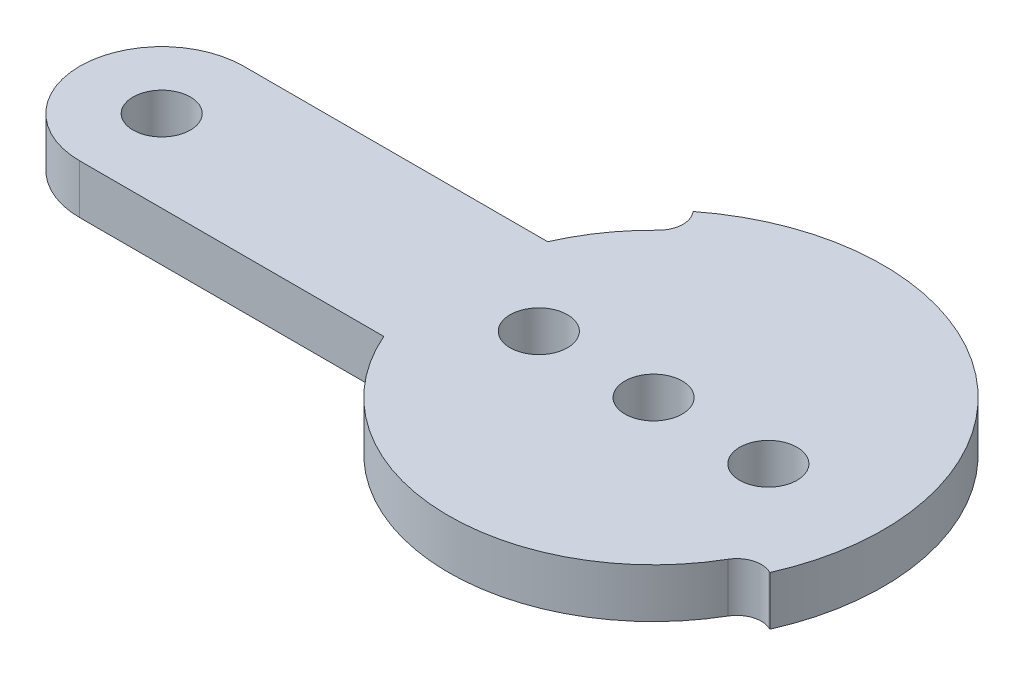
from build123d import *

# Parameters (mm, degrees)
SKETCH_1_R          = 1.75
EXTRUDE_1_DEPTH     = 3
SKETCH_2_R          = 6
EXTRUDE_2_DEPTH     = 3
SKETCH_3_R          = 1.75
CUT_EXTRUDE_1_DEPTH = 7


with BuildPart() as part:
    # Эскиз1 → Бобышка-Вытянуть1 (new body)
    with BuildSketch(Plane(origin=(0, 0, 0), x_dir=(1, 0, 0), z_dir=(0, 1, 0))):
        with BuildLine():
            Line((-30, 5), (-11.456439237, 5))
            ThreePointArc((-11.456439237, 5), (-10.2750901, 7.118463559), (-8.706840344, 8.968886844))
            ThreePointArc((-8.706840344, 8.968886844), (-8.255178852, 9.942485712), (-8.569645055, 10.968645479))
            Line((-8.569645055, 10.968645479), (-8.619260655, 11.03215055))
            ThreePointArc((-8.619260655, 11.03215055), (8.619260655, 11.03215055), (12.789636407, -5.694313003))
            Line((12.789636407, -5.694313003), (12.716014607, -5.661534466))
            ThreePointArc((12.716014607, -5.661534466), (11.644259912, -5.604659769), (10.808847895, -6.278439868))
            ThreePointArc((10.808847895, -6.278439868), (-0.716551297, -12.47944527), (-11.456439237, -5))
            Line((-11.456439237, -5), (-30, -5))
            ThreePointArc((-30, -5), (-35, 0), (-30, 5))
        make_face()
        with Locations((-30, 0)):
            Circle(SKETCH_1_R, mode=Mode.SUBTRACT)
    extrude(amount=EXTRUDE_1_DEPTH)

    # Эскиз2 → Бобышка-Вытянуть2 (add)
    with BuildSketch(Plane.XZ):
        Circle(SKETCH_2_R)
    extrude(amount=EXTRUDE_2_DEPTH)

    # Эскиз3 → Вырез-Вытянуть1 (cut, through all)
    with BuildSketch(Plane.XZ.offset(3)):
        Circle(SKETCH_3_R)
        with Locations((-7, 0)):
            Circle(SKETCH_3_R)
        with Locations((7, 0)):
            Circle(SKETCH_3_R)
    extrude(amount=-CUT_EXTRUDE_1_DEPTH, mode=Mode.SUBTRACT)


solid = part.part
